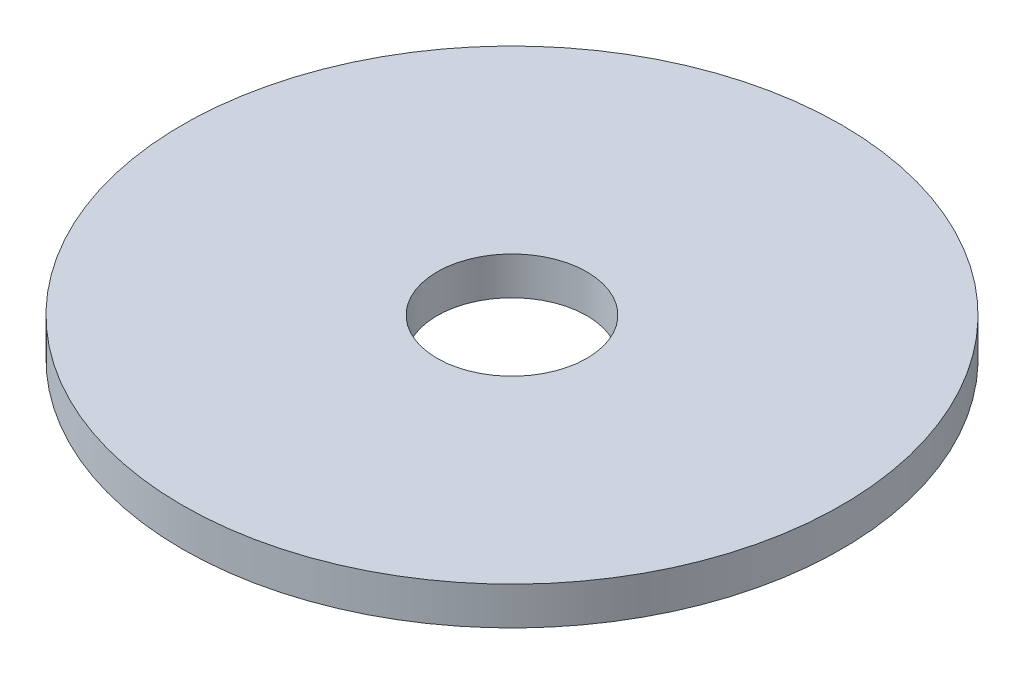
from build123d import *

# Parameters (mm, degrees)
SKETCH1_R           = 83.82
BOSS_EXTRUDE1_DEPTH = 4.826
SKETCH2_R           = 19.05
CUT_EXTRUDE1_DEPTH  = 9.652


with BuildPart() as part:
    # Sketch1 → Boss-Extrude1 (new body, symmetric)
    with BuildSketch(Plane(origin=(0, 0, 0), x_dir=(1, 0, 0), z_dir=(0, 1, 0))):
        Circle(SKETCH1_R)
    extrude(amount=BOSS_EXTRUDE1_DEPTH, both=True)

    # Sketch2 → Cut-Extrude1 (cut)
    with BuildSketch(Plane.XZ.offset(4.826)):
        Circle(SKETCH2_R)
    extrude(amount=-CUT_EXTRUDE1_DEPTH, mode=Mode.SUBTRACT)


solid = part.part
